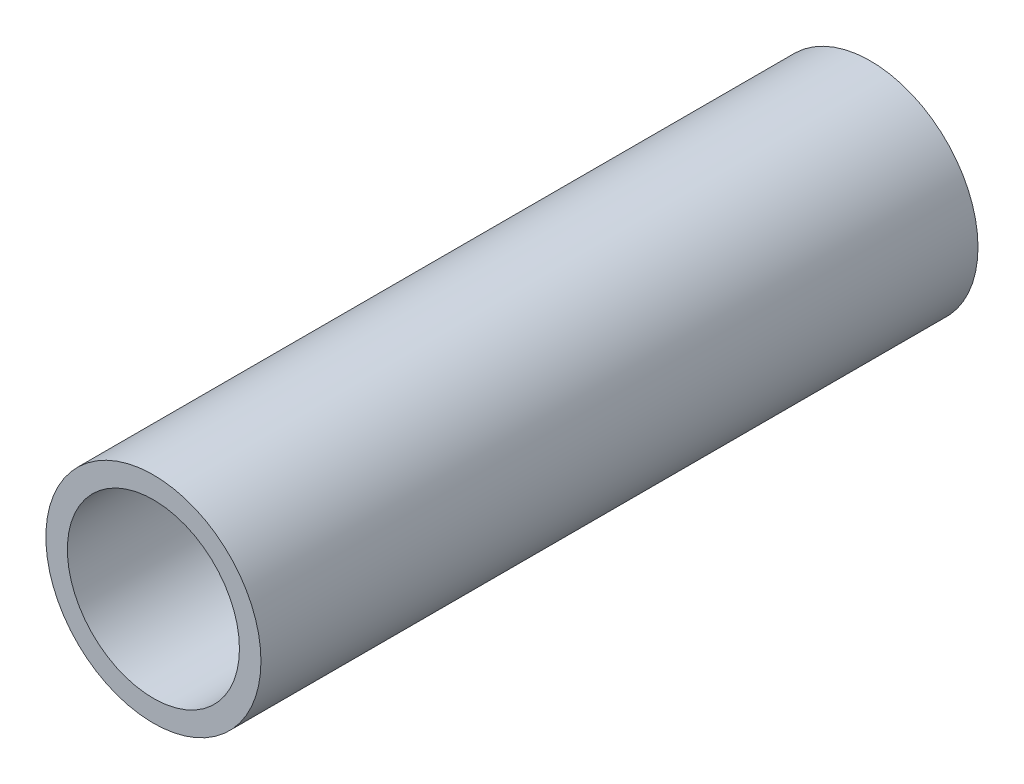
from build123d import *

# Parameters (mm, degrees)
SKETCH1_R           = 7.5
SKETCH1_R_2         = 6
BOSS_EXTRUDE1_DEPTH = 50


with BuildPart() as part:
    # Sketch1 → Boss-Extrude1 (new body)
    with BuildSketch(Plane.XY):
        Circle(SKETCH1_R)
        Circle(SKETCH1_R_2, mode=Mode.SUBTRACT)
    extrude(amount=BOSS_EXTRUDE1_DEPTH)


solid = part.part
